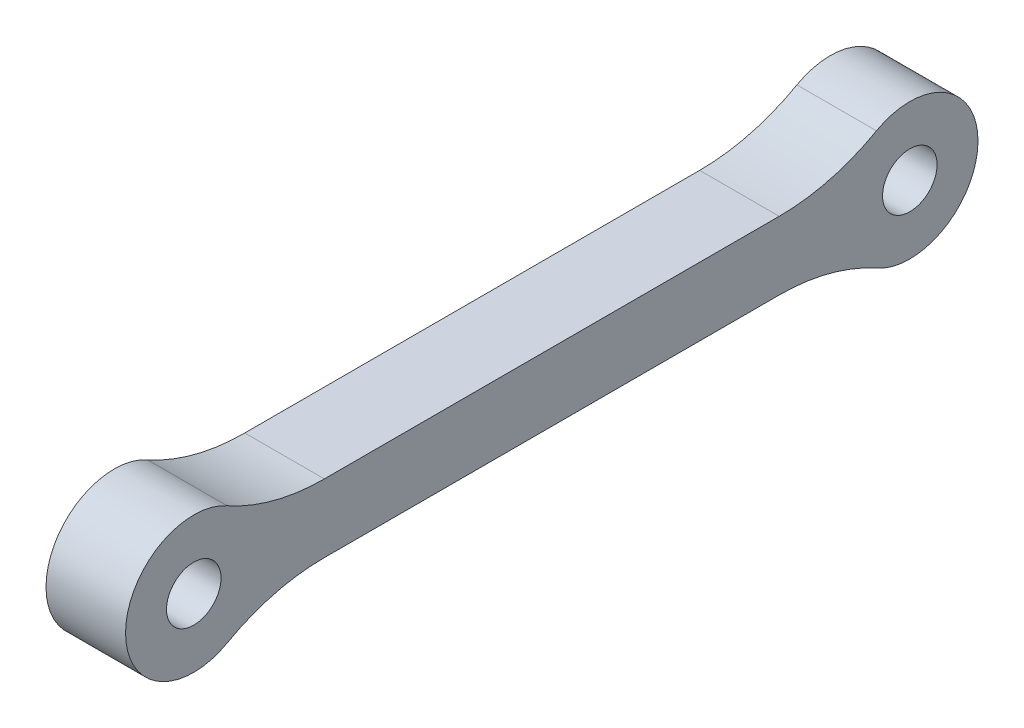
from build123d import *

# Parameters (mm, degrees)
SKETCH1_R           = 1.371428571
BOSS_EXTRUDE1_DEPTH = 4
FILLET1_R           = 10


with BuildPart() as part:
    # Sketch1 → Boss-Extrude1 (new body)
    with BuildSketch(Plane(origin=(0, 0, 0), x_dir=(0, 0, -1), z_dir=(1, 0, 0))):
        with BuildLine():
            Line((18, 1.714285714), (33.030770044, 1.714285714))
            ThreePointArc((33.030770044, 1.714285714), (39.428571429, 0), (33.030770044, -1.714285714))
            Line((33.030770044, -1.714285714), (18, -1.714285714))
            Line((18, -1.714285714), (2.969229956, -1.714285714))
            ThreePointArc((2.969229956, -1.714285714), (-3.428571429, 0), (2.969229956, 1.714285714))
            Line((2.969229956, 1.714285714), (18, 1.714285714))
        make_face()
        Circle(SKETCH1_R, mode=Mode.SUBTRACT)
        with Locations((36, 0)):
            Circle(SKETCH1_R, mode=Mode.SUBTRACT)
    extrude(amount=BOSS_EXTRUDE1_DEPTH)

    # Fillet1
    fillet1_edges = [part.edges().sort_by_distance(p)[0] for p in [
        (2, 1.714285714, -33.030770044),
        (2, -1.714285714, -33.030770044),
        (2, -1.714285714, -2.969229956),
        (2, 1.714285714, -2.969229956),
    ]]
    fillet(fillet1_edges, radius=FILLET1_R)


solid = part.part
